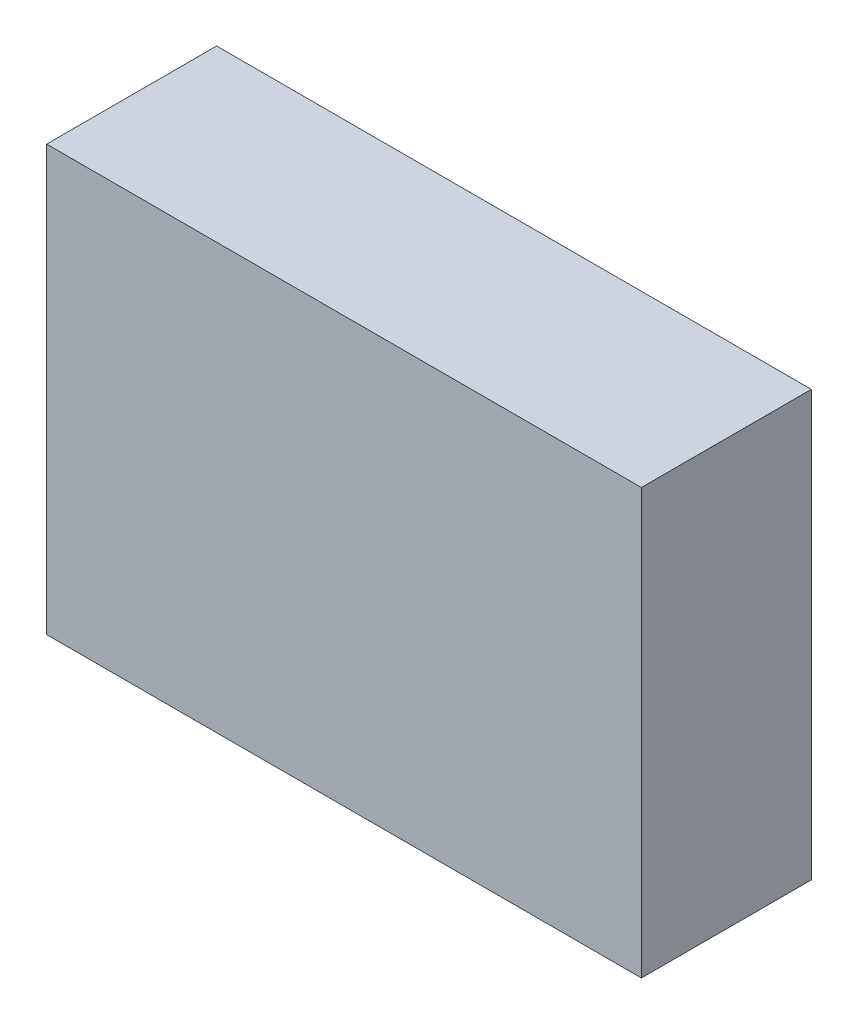
from build123d import *

# Parameters (mm, degrees)
SKETCH1_W           = 177.8
SKETCH1_H           = 127
BOSS_EXTRUDE1_DEPTH = 50.8


with BuildPart() as part:
    # Sketch1 → Boss-Extrude1 (new body)
    with BuildSketch(Plane.XY):
        Rectangle(SKETCH1_W, SKETCH1_H)
    extrude(amount=BOSS_EXTRUDE1_DEPTH)


solid = part.part
